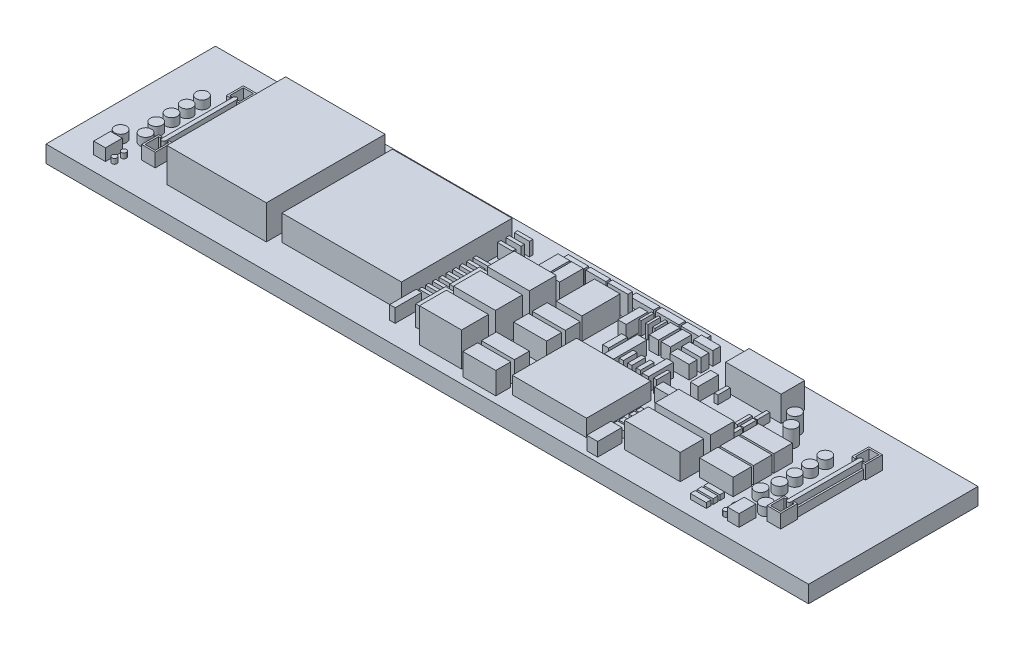
from build123d import *

# Parameters (mm, degrees)
SKETCH1_W            = 45
SKETCH1_H            = 10
BOSS_EXTRUDE1_DEPTH  = 1
BOSS_EXTRUDE4_DEPTH  = 0.8
SKETCH8_W            = 0.10988021
SKETCH8_H            = 4
SKETCH8_W_2          = 0.109880211
BOSS_EXTRUDE5_DEPTH  = 0.5
BOSS_EXTRUDE6_DEPTH  = 0.8
MIRROR2_COPY_1_DEPTH = 0.8
SKETCH10_W           = 0.694795858
SKETCH10_H           = 0.992565511
BOSS_EXTRUDE7_DEPTH  = 0.7
SKETCH11_R           = 0.35
BOSS_EXTRUDE8_DEPTH  = 0.5
SKETCH11_3_R         = 0.15
BOSS_EXTRUDE9_DEPTH  = 0.3
SKETCH12_R           = 0.35
BOSS_EXTRUDE10_DEPTH = 0.5
SKETCH13_W           = 0.942937235
SKETCH13_H           = 0.290163041
BOSS_EXTRUDE11_DEPTH = 0.3
SKETCH14_R           = 0.35
SKETCH14_W           = 1.985131023
SKETCH14_H           = 1.091822062
BOSS_EXTRUDE12_DEPTH = 1
SKETCH15_W           = 3.275466186
SKETCH15_H           = 1.389591715
BOSS_EXTRUDE13_DEPTH = 1.5
SKETCH15_3_W         = 0.198513102
SKETCH15_3_H         = 0.741233477
BOSS_EXTRUDE14_DEPTH = 0.5
LPATTERN1_COUNT      = 3
LPATTERN1_PITCH      = 0.8
SKETCH16_W           = 3.275466186
SKETCH16_H           = 1.389591716
BOSS_EXTRUDE15_DEPTH = 1.5
SKETCH17_W           = 0.97102713
SKETCH17_H           = 0.248635513
SKETCH17_W_2         = 0.210354518
SKETCH17_H_2         = 0.736240813
SKETCH17_W_3         = 0.174254224
SKETCH17_H_3         = 0.883530912
BOSS_EXTRUDE16_DEPTH = 0.5
SKETCH19_W           = 0.642612632
SKETCH19_H           = 1.429790745
BOSS_EXTRUDE17_DEPTH = 0.8
SKETCH20_W           = 0.987246274
SKETCH20_H           = 0.313418882
BOSS_EXTRUDE18_DEPTH = 0.4
LPATTERN2_COUNT      = 2
LPATTERN2_PITCH      = 1
SKETCH21_W           = 1.328097077
SKETCH21_H           = 0.514142512
SKETCH21_W_2         = 0.463971968
SKETCH21_H_2         = 1.198500025
BOSS_EXTRUDE19_DEPTH = 0.8
SKETCH22_W           = 4.383039341
SKETCH22_H           = 3.793998422
BOSS_EXTRUDE20_DEPTH = 1
SKETCH23_W           = 0.244074754
SKETCH23_H           = 0.812322543
SKETCH23_W_2         = 0.185241766
SKETCH23_W_3         = 0.38493457
SKETCH23_H_2         = 1.467242489
SKETCH23_W_4         = 0.551812517
SKETCH23_H_3         = 1.95601937
SKETCH23_W_5         = 0.348956443
SKETCH23_H_4         = 1.118736649
SKETCH23_W_6         = 1.133296277
SKETCH23_H_5         = 0.46990115
BOSS_EXTRUDE21_DEPTH = 0.8
SKETCH24_W           = 0.555322576
SKETCH24_H           = 1.254440453
SKETCH24_W_2         = 0.139287642
SKETCH24_H_2         = 0.748887031
SKETCH24_W_3         = 0.486956825
SKETCH24_H_3         = 1.28459238
BOSS_EXTRUDE22_DEPTH = 0.8
SKETCH25_W           = 1.392398025
SKETCH25_H           = 0.383061514
BOSS_EXTRUDE23_DEPTH = 0.5
SKETCH26_W           = 1.948011324
SKETCH26_H           = 0.882041086
BOSS_EXTRUDE24_DEPTH = 1.3
LPATTERN3_COUNT      = 2
LPATTERN3_PITCH      = 3
SKETCH27_W           = 1.190544255
SKETCH27_H           = 0.278920999
SKETCH27_W_2         = 1.518247914
SKETCH27_H_2         = 2.256483045
BOSS_EXTRUDE25_DEPTH = 1.3
SKETCH28_W           = 2.481413778
SKETCH28_H           = 1.588104818
BOSS_EXTRUDE26_DEPTH = 2
SKETCH29_W           = 0.694795858
SKETCH29_H           = 1.395369163
BOSS_EXTRUDE27_DEPTH = 1.5
SKETCH30_W           = 0.16488814
SKETCH30_H           = 0.934366128
BOSS_EXTRUDE28_DEPTH = 0.8
SKETCH31_W           = 0.70461433
SKETCH31_H           = 1.761535826
BOSS_EXTRUDE29_DEPTH = 1.2
SKETCH32_W           = 7.057861422
SKETCH32_H           = 6.521460584
BOSS_EXTRUDE30_DEPTH = 1.5
SKETCH33_W           = 0.325168333
SKETCH33_H           = 1.560807998
BOSS_EXTRUDE31_DEPTH = 0.8
SKETCH34_W           = 0.912205365
SKETCH34_H           = 0.190353801
BOSS_EXTRUDE32_DEPTH = 0.7
SKETCH35_W           = 0.890564826
SKETCH35_H           = 0.200377086
BOSS_EXTRUDE33_DEPTH = 0.8
SKETCH36_W           = 5.870321645
SKETCH36_H           = 7.010056176
BOSS_EXTRUDE34_DEPTH = 2


with BuildPart() as part:
    # Sketch1 → Boss-Extrude1 (new body)
    with BuildSketch(Plane(origin=(0, 0, 0), x_dir=(1, 0, 0), z_dir=(0, 1, 0))):
        Rectangle(SKETCH1_W, SKETCH1_H)
    extrude(amount=BOSS_EXTRUDE1_DEPTH)

    # Sketch7 → Boss-Extrude4 (add)
    with BuildSketch(Plane(origin=(0, 1, 0), x_dir=(1, 0, 0), z_dir=(0, 1, 0))):
        Polygon((18.854851883, 3), (18.054851883, 3), (18.054851883, 2), (18.254851883, 2), (18.254851883, 2.1), (18.154851883, 2.1), (18.154851883, 2.9), (18.754851883, 2.9), (18.754851883, 2.1), (18.654851883, 2.1), (18.654851883, 2), (18.854851883, 2), align=None)
    boss_extrude4 = extrude(amount=BOSS_EXTRUDE4_DEPTH)

    # Sketch8 → Boss-Extrude5 (add)
    with BuildSketch(Plane(origin=(0, 1, 0), x_dir=(1, 0, 0), z_dir=(0, 1, 0))):
        with Locations((18.209791988, 0)):
            Rectangle(SKETCH8_W, SKETCH8_H)
        with Locations((18.699911777, 0)):
            Rectangle(SKETCH8_W_2, SKETCH8_H)
    boss_extrude5 = extrude(amount=BOSS_EXTRUDE5_DEPTH)

    # Mirror1: Boss-Extrude4 across plane
    add(boss_extrude4.mirror(Plane.XY))

    # Sketch9 → Boss-Extrude6 (add)
    with BuildSketch(Plane(origin=(0, 1, 0), x_dir=(1, 0, 0), z_dir=(0, 1, 0))):
        with BuildLine():
            Line((18.573746966, 2.1), (18.573746966, -2.1))
            ThreePointArc((18.573746966, -2.1), (18.454851883, -2.218895083), (18.335956799, -2.1))
            Line((18.335956799, -2.1), (18.335956799, 2.1))
            ThreePointArc((18.335956799, 2.1), (18.454851883, 2.218895083), (18.573746966, 2.1))
        make_face()
    boss_extrude6 = extrude(amount=BOSS_EXTRUDE6_DEPTH)

    # Mirror2: Boss-Extrude4, Boss-Extrude5, Boss-Extrude6 across plane
    add(boss_extrude4.mirror(Plane(origin=(0, 0, 0), x_dir=(0, 0, 1), z_dir=(1, 0, 0))))
    add(boss_extrude5.mirror(Plane(origin=(0, 0, 0), x_dir=(0, 0, 1), z_dir=(1, 0, 0))))
    add(boss_extrude6.mirror(Plane(origin=(0, 0, 0), x_dir=(0, 0, 1), z_dir=(1, 0, 0))))

    # Mirror2 copy 1 sketch → Mirror2 copy 1 (add)
    with BuildSketch(Plane(origin=(0, 1, 0), x_dir=(-1, 0, 0), z_dir=(0, 1, 0))):
        Polygon((18.854851883, 3), (18.054851883, 3), (18.054851883, 2), (18.254851883, 2), (18.254851883, 2.1), (18.154851883, 2.1), (18.154851883, 2.9), (18.754851883, 2.9), (18.754851883, 2.1), (18.654851883, 2.1), (18.654851883, 2), (18.854851883, 2), align=None)
    extrude(amount=MIRROR2_COPY_1_DEPTH)

    # Sketch10 → Boss-Extrude7 (add)
    with BuildSketch(Plane(origin=(0, 1, 0), x_dir=(1, 0, 0), z_dir=(0, 1, 0))):
        with Locations((17.19619748, -3.647678254)):
            Rectangle(SKETCH10_W, SKETCH10_H)
    boss_extrude7 = extrude(amount=BOSS_EXTRUDE7_DEPTH)

    # Sketch11 → Boss-Extrude8 (add)
    with BuildSketch(Plane(origin=(0, 1, 0), x_dir=(1, 0, 0), z_dir=(0, 1, 0))):
        with Locations((17.543595409, -2.555538539)):
            Circle(SKETCH11_R)
    boss_extrude8 = extrude(amount=BOSS_EXTRUDE8_DEPTH)

    # Sketch11_3 → Boss-Extrude9 (add)
    with BuildSketch(Plane(origin=(0, 1, 0), x_dir=(1, 0, 0), z_dir=(0, 1, 0))):
        with Locations((16.547748779, -3.907960345)):
            Circle(SKETCH11_3_R)
        with Locations((16.547748779, -3.356293789)):
            Circle(SKETCH11_3_R)
    boss_extrude9 = extrude(amount=BOSS_EXTRUDE9_DEPTH)

    # Sketch12 → Boss-Extrude10 (add)
    with BuildSketch(Plane(origin=(0, 1, 0), x_dir=(1, 0, 0), z_dir=(0, 1, 0))):
        with Locations((16.64786927, -1.978391462)):
            Circle(SKETCH12_R)
        with Locations((16.890278045, -1.103026442)):
            Circle(SKETCH12_R)
        with Locations((16.890278045, -0.203026442)):
            Circle(SKETCH12_R)
        with Locations((16.890278045, 0.696973558)):
            Circle(SKETCH12_R)
        with Locations((16.890278045, 1.596973558)):
            Circle(SKETCH12_R)
    boss_extrude10 = extrude(amount=BOSS_EXTRUDE10_DEPTH)

    # Sketch13 → Boss-Extrude11 (add)
    with BuildSketch(Plane(origin=(0, 1, 0), x_dir=(1, 0, 0), z_dir=(0, 1, 0))):
        with Locations((15.136624044, -3.998879489)):
            Rectangle(SKETCH13_W, SKETCH13_H)
        with Locations((15.136624044, -3.598879489)):
            Rectangle(SKETCH13_W, SKETCH13_H)
        with Locations((15.136624044, -3.198879489)):
            Rectangle(SKETCH13_W, SKETCH13_H)
    extrude(amount=BOSS_EXTRUDE11_DEPTH)

    # Sketch14 → Boss-Extrude12 (add)
    with BuildSketch(Plane(origin=(0, 1, 0), x_dir=(1, 0, 0), z_dir=(0, 1, 0))):
        with Locations((14.814040254, 1.662547231)):
            Circle(SKETCH14_R)
        with Locations((14.274328528, 2.422746884)):
            Circle(SKETCH14_R)
        with Locations((14.814040253, -2.208458262)):
            Rectangle(SKETCH14_W, SKETCH14_H)
        with Locations((14.814040253, -1.008458262)):
            Rectangle(SKETCH14_W, SKETCH14_H)
        with Locations((14.814040253, 0.191541738)):
            Rectangle(SKETCH14_W, SKETCH14_H)
    extrude(amount=BOSS_EXTRUDE12_DEPTH)

    # Sketch15 → Boss-Extrude13 (add)
    with BuildSketch(Plane(origin=(0, 1, 0), x_dir=(1, 0, 0), z_dir=(0, 1, 0))):
        with Locations((11.83634372, -1.053625844)):
            Rectangle(SKETCH15_W, SKETCH15_H)
        with Locations((11.83634372, -2.853625845)):
            Rectangle(SKETCH15_W, SKETCH15_H)
    extrude(amount=BOSS_EXTRUDE13_DEPTH)

    # Sketch15_3 → Boss-Extrude14 (add)
    with BuildSketch(Plane(origin=(0, 1, 0), x_dir=(1, 0, 0), z_dir=(0, 1, 0))):
        with Locations((12.973806693, 0.171408044)):
            Rectangle(SKETCH15_3_W, SKETCH15_3_H)
    boss_extrude14 = extrude(amount=BOSS_EXTRUDE14_DEPTH)

    # LPattern1: Boss-Extrude14 ×3
    with Locations(*[(0, 0, -i * LPATTERN1_PITCH) for i in range(1, LPATTERN1_COUNT)]):
        add(boss_extrude14)

    # Sketch16 → Boss-Extrude15 (add)
    with BuildSketch(Plane(origin=(0, 1, 0), x_dir=(1, 0, 0), z_dir=(0, 1, 0))):
        with Locations((11.83634372, 3.101767222)):
            Rectangle(SKETCH16_W, SKETCH16_H)
    extrude(amount=BOSS_EXTRUDE15_DEPTH)

    # Sketch17 → Boss-Extrude16 (add)
    with BuildSketch(Plane(origin=(0, 1, 0), x_dir=(1, 0, 0), z_dir=(0, 1, 0))):
        with Locations((12.164091396, -0.11141193)):
            Rectangle(SKETCH17_W, SKETCH17_H)
        with Locations((10.546991037, 1.86066168)):
            Rectangle(SKETCH17_W_2, SKETCH17_H_2)
        with Locations((12.649604961, 1.000880504)):
            Rectangle(SKETCH17_W_3, SKETCH17_H_3)
    extrude(amount=BOSS_EXTRUDE16_DEPTH)

    # Sketch19 → Boss-Extrude17 (add)
    with BuildSketch(Plane(origin=(0, 1, 0), x_dir=(1, 0, 0), z_dir=(0, 1, 0))):
        with Locations((9.459055748, -4.009640519)):
            Rectangle(SKETCH19_W, SKETCH19_H)
    extrude(amount=BOSS_EXTRUDE17_DEPTH)

    # Sketch20 → Boss-Extrude18 (add)
    with BuildSketch(Plane(origin=(0, 1, 0), x_dir=(1, 0, 0), z_dir=(0, 1, 0))):
        with Locations((9.403951943, -2.444389)):
            Rectangle(SKETCH20_W, SKETCH20_H)
        with Locations((9.403951943, -2.844389)):
            Rectangle(SKETCH20_W, SKETCH20_H)
    boss_extrude18 = extrude(amount=BOSS_EXTRUDE18_DEPTH)

    # LPattern2: Boss-Extrude18 ×2
    with Locations(*[(0, 0, -i * LPATTERN2_PITCH) for i in range(1, LPATTERN2_COUNT)]):
        add(boss_extrude18)

    # Sketch21 → Boss-Extrude19 (add)
    with BuildSketch(Plane(origin=(0, 1, 0), x_dir=(1, 0, 0), z_dir=(0, 1, 0))):
        with Locations((9.329265023, 0)):
            Rectangle(SKETCH21_W, SKETCH21_H)
        with Locations((9.709193194, 1.647277331)):
            Rectangle(SKETCH21_W_2, SKETCH21_H_2)
    extrude(amount=BOSS_EXTRUDE19_DEPTH)

    # Sketch23 → Boss-Extrude21 (add)
    with BuildSketch(Plane(origin=(0, 1, 0), x_dir=(1, 0, 0), z_dir=(0, 1, 0))):
        with Locations((6.781018385, 0.575790127)):
            Rectangle(SKETCH23_W, SKETCH23_H)
        with Locations((8.275882436, 0.575790127)):
            Rectangle(SKETCH23_W_2, SKETCH23_H)
        with Locations((7.777236615, 0.820178568)):
            Rectangle(SKETCH23_W_3, SKETCH23_H_2)
        with Locations((7.281018385, 0.575790127)):
            Rectangle(SKETCH23_W, SKETCH23_H)
        with Locations((6.281018385, 0.575790127)):
            Rectangle(SKETCH23_W, SKETCH23_H)
        with Locations((5.763442971, 0.932769197)):
            Rectangle(SKETCH23_W_4, SKETCH23_H_3)
        with Locations((5.155605295, 0.932769198)):
            Rectangle(SKETCH23_W_5, SKETCH23_H_4)
        with Locations((7.969703901, 2.145729457)):
            Rectangle(SKETCH23_W_6, SKETCH23_H_5)
        with Locations((7.969703901, 2.845729457)):
            Rectangle(SKETCH23_W_6, SKETCH23_H_5)
        with Locations((7.969703901, 3.545729457)):
            Rectangle(SKETCH23_W_6, SKETCH23_H_5)
    extrude(amount=BOSS_EXTRUDE21_DEPTH)

    # Sketch24 → Boss-Extrude22 (add)
    with BuildSketch(Plane(origin=(0, 1, 0), x_dir=(1, 0, 0), z_dir=(0, 1, 0))):
        with Locations((6.819904018, 2.878617548)):
            Rectangle(SKETCH24_W, SKETCH24_H)
        with Locations((6.119904018, 2.878617548)):
            Rectangle(SKETCH24_W, SKETCH24_H)
        with Locations((5.217218008, 3.112281646)):
            Rectangle(SKETCH24_W_2, SKETCH24_H_2)
        with Locations((5.617218008, 3.112281646)):
            Rectangle(SKETCH24_W_2, SKETCH24_H_2)
        with Locations((4.817218008, 3.112281646)):
            Rectangle(SKETCH24_W_2, SKETCH24_H_2)
        with Locations((4.394849179, 2.73783813)):
            Rectangle(SKETCH24_W_3, SKETCH24_H_3)
    extrude(amount=BOSS_EXTRUDE22_DEPTH)

    # Sketch25 → Boss-Extrude23 (add)
    with BuildSketch(Plane(origin=(0, 1, 0), x_dir=(1, 0, 0), z_dir=(0, 1, 0))):
        with Locations((6.720520688, 4.12620004)):
            Rectangle(SKETCH25_W, SKETCH25_H)
        with Locations((5.220520688, 4.12620004)):
            Rectangle(SKETCH25_W, SKETCH25_H)
        with Locations((3.720520688, 4.12620004)):
            Rectangle(SKETCH25_W, SKETCH25_H)
    extrude(amount=BOSS_EXTRUDE23_DEPTH)

    # Sketch26 → Boss-Extrude24 (add)
    with BuildSketch(Plane(origin=(0, 1, 0), x_dir=(1, 0, 0), z_dir=(0, 1, 0))):
        with Locations((2.67062358, -4.159994299)):
            Rectangle(SKETCH26_W, SKETCH26_H)
        with Locations((2.67062358, -3.059994299)):
            Rectangle(SKETCH26_W, SKETCH26_H)
    boss_extrude24 = extrude(amount=BOSS_EXTRUDE24_DEPTH)

    # LPattern3: Boss-Extrude24 ×2
    with Locations(*[(0, 0, -i * LPATTERN3_PITCH) for i in range(1, LPATTERN3_COUNT)]):
        add(boss_extrude24)

    # Sketch27 → Boss-Extrude25 (add)
    with BuildSketch(Plane(origin=(0, 1, 0), x_dir=(1, 0, 0), z_dir=(0, 1, 0))):
        with Locations((1.756460457, 3.326732579)):
            Rectangle(SKETCH27_W, SKETCH27_H)
        with Locations((2.640303755, 1.853765938)):
            Rectangle(SKETCH27_W_2, SKETCH27_H_2)
        with Locations((3.056460456, 3.326732579)):
            Rectangle(SKETCH27_W, SKETCH27_H)
        with Locations((0.456460457, 3.326732579)):
            Rectangle(SKETCH27_W, SKETCH27_H)
    extrude(amount=BOSS_EXTRUDE25_DEPTH)

    # Sketch28 → Boss-Extrude26 (add)
    with BuildSketch(Plane(origin=(0, 1, 0), x_dir=(1, 0, 0), z_dir=(0, 1, 0))):
        with Locations((0.024814138, -1.449165151)):
            Rectangle(SKETCH28_W, SKETCH28_H)
        with Locations((0.024814138, -3.449165151)):
            Rectangle(SKETCH28_W, SKETCH28_H)
        with Locations((0.024814138, 0.550834849)):
            Rectangle(SKETCH28_W, SKETCH28_H)
    extrude(amount=BOSS_EXTRUDE26_DEPTH)

    # Sketch29 → Boss-Extrude27 (add)
    with BuildSketch(Plane(origin=(0, 1, 0), x_dir=(1, 0, 0), z_dir=(0, 1, 0))):
        with Locations((0.065392432, 2.298249429)):
            Rectangle(SKETCH29_W, SKETCH29_H)
        with Locations((0.865392432, 2.298249429)):
            Rectangle(SKETCH29_W, SKETCH29_H)
    extrude(amount=BOSS_EXTRUDE27_DEPTH)

    # Sketch30 → Boss-Extrude28 (add)
    with BuildSketch(Plane(origin=(0, 1, 0), x_dir=(1, 0, 0), z_dir=(0, 1, 0))):
        with Locations((-0.521315673, 2.958688447)):
            Rectangle(SKETCH30_W, SKETCH30_H)
        with Locations((-0.521315673, 1.958688447)):
            Rectangle(SKETCH30_W, SKETCH30_H)
    extrude(amount=BOSS_EXTRUDE28_DEPTH)

    # Sketch31 → Boss-Extrude29 (add)
    with BuildSketch(Plane(origin=(0, 1, 0), x_dir=(1, 0, 0), z_dir=(0, 1, 0))):
        with Locations((-1.871445633, -0.57668492)):
            Rectangle(SKETCH31_W, SKETCH31_H)
        with Locations((-1.871445633, -2.57668492)):
            Rectangle(SKETCH31_W, SKETCH31_H)
    extrude(amount=BOSS_EXTRUDE29_DEPTH)

    # Sketch33 → Boss-Extrude31 (add)
    with BuildSketch(Plane(origin=(0, 1, 0), x_dir=(1, 0, 0), z_dir=(0, 1, 0))):
        with Locations((-3.191932865, -3.084985691)):
            Rectangle(SKETCH33_W, SKETCH33_H)
    extrude(amount=BOSS_EXTRUDE31_DEPTH)

    # Sketch34 → Boss-Extrude32 (add)
    with BuildSketch(Plane(origin=(0, 1, 0), x_dir=(1, 0, 0), z_dir=(0, 1, 0))):
        with Locations((-2.932665215, -1.614303792)):
            Rectangle(SKETCH34_W, SKETCH34_H)
        with Locations((-2.932665215, -2.014303792)):
            Rectangle(SKETCH34_W, SKETCH34_H)
        with Locations((-2.932665215, -1.214303792)):
            Rectangle(SKETCH34_W, SKETCH34_H)
        with Locations((-2.932665215, -0.814303791)):
            Rectangle(SKETCH34_W, SKETCH34_H)
        with Locations((-2.932665215, -0.414303792)):
            Rectangle(SKETCH34_W, SKETCH34_H)
        with Locations((-2.932665215, -0.014303792)):
            Rectangle(SKETCH34_W, SKETCH34_H)
        with Locations((-2.932665215, 0.385696209)):
            Rectangle(SKETCH34_W, SKETCH34_H)
        with Locations((-2.932665215, 0.785696209)):
            Rectangle(SKETCH34_W, SKETCH34_H)
        with Locations((-2.932665215, 1.185696209)):
            Rectangle(SKETCH34_W, SKETCH34_H)
    extrude(amount=BOSS_EXTRUDE32_DEPTH)

    # Sketch35 → Boss-Extrude33 (add)
    with BuildSketch(Plane(origin=(0, 1, 0), x_dir=(1, 0, 0), z_dir=(0, 1, 0))):
        with Locations((-2.905811784, 3.089074118)):
            Rectangle(SKETCH35_W, SKETCH35_H)
        with Locations((-2.905811784, 2.589074118)):
            Rectangle(SKETCH35_W, SKETCH35_H)
        with Locations((-2.905811784, 3.589074118)):
            Rectangle(SKETCH35_W, SKETCH35_H)
    extrude(amount=BOSS_EXTRUDE33_DEPTH)

    # Mirror3: Boss-Extrude7, Boss-Extrude8, Boss-Extrude9, Boss-Extrude10 across plane
    add(boss_extrude7.mirror(Plane(origin=(-1.5, 0, 0), x_dir=(0, 0, 1), z_dir=(1, 0, 0))))
    add(boss_extrude8.mirror(Plane(origin=(-1.5, 0, 0), x_dir=(0, 0, 1), z_dir=(1, 0, 0))))
    add(boss_extrude9.mirror(Plane(origin=(-1.5, 0, 0), x_dir=(0, 0, 1), z_dir=(1, 0, 0))))
    add(boss_extrude10.mirror(Plane(origin=(-1.5, 0, 0), x_dir=(0, 0, 1), z_dir=(1, 0, 0))))


with BuildPart() as body_2:
    # Sketch22 → Boss-Extrude20 (new body)
    with BuildSketch(Plane(origin=(0, 1, 0), x_dir=(1, 0, 0), z_dir=(0, 1, 0))):
        with Locations((6.268318033, -2.164165767)):
            Rectangle(SKETCH22_W, SKETCH22_H)
    extrude(amount=BOSS_EXTRUDE20_DEPTH)


with BuildPart() as body_3:
    # Sketch32 → Boss-Extrude30 (new body)
    with BuildSketch(Plane(origin=(0, 1, 0), x_dir=(1, 0, 0), z_dir=(0, 1, 0))):
        with Locations((-6.984893084, 0.196443425)):
            Rectangle(SKETCH32_W, SKETCH32_H)
    extrude(amount=BOSS_EXTRUDE30_DEPTH)


with BuildPart() as body_4:
    # Sketch36 → Boss-Extrude34 (new body)
    with BuildSketch(Plane(origin=(0, 1, 0), x_dir=(1, 0, 0), z_dir=(0, 1, 0))):
        with Locations((-13.928194549, 0)):
            Rectangle(SKETCH36_W, SKETCH36_H)
    extrude(amount=BOSS_EXTRUDE34_DEPTH)


solid = Compound([part.part, body_2.part, body_3.part, body_4.part])
